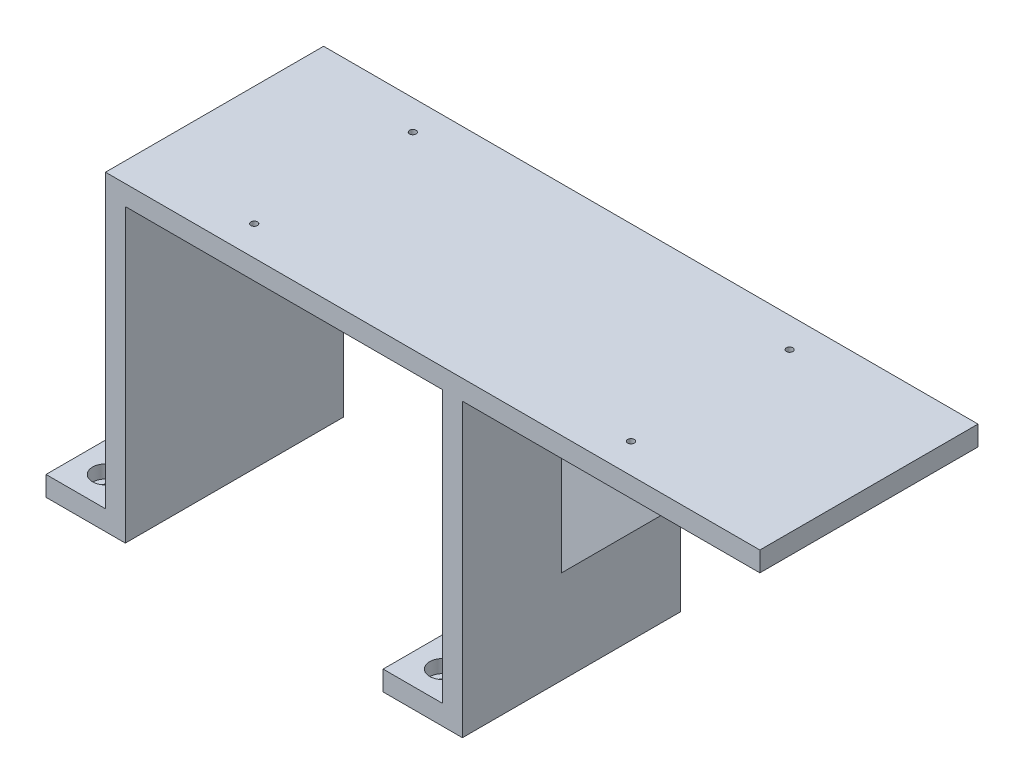
from build123d import *

# Parameters (mm, degrees)
BOSS_EXTRUDE1_DEPTH = 110
SKETCH2_R           = 3.3
CUT_EXTRUDE1_DEPTH  = 11
SKETCH3_R           = 6.5
CUT_EXTRUDE2_DEPTH  = 6.6
SKETCH5_W           = 150
SKETCH5_H           = 10
BOSS_EXTRUDE2_DEPTH = 110
BOSS_EXTRUDE3_DEPTH = 5
M4_TAPPED_HOLE1_D   = 3.3


with BuildPart() as part:
    # Sketch1 → Boss-Extrude1 (new body)
    with BuildSketch(Plane.XY):
        Polygon((0, 0), (30, 0), (30, 147), (210, 147), (210, -10), (170, -10), (170, 0), (200, 0), (200, 137), (40, 137), (40, -10), (0, -10), align=None)
    extrude(amount=BOSS_EXTRUDE1_DEPTH)

    # Sketch2 → Cut-Extrude1 (cut, through all)
    with BuildSketch(Plane(origin=(0, 0, 0), x_dir=(1, 0, 0), z_dir=(0, 1, 0))):
        with Locations((15, -15)):
            Circle(SKETCH2_R)
        with Locations((15, -95)):
            Circle(SKETCH2_R)
        with Locations((185, -95)):
            Circle(SKETCH2_R)
        with Locations((185, -15)):
            Circle(SKETCH2_R)
    extrude(amount=-CUT_EXTRUDE1_DEPTH, mode=Mode.SUBTRACT)

    # Sketch3 → Cut-Extrude2 (cut)
    with BuildSketch(Plane(origin=(0, 0, 0), x_dir=(1, 0, 0), z_dir=(0, 1, 0))):
        with Locations((15, -15)):
            Circle(SKETCH3_R)
        with Locations((15, -95)):
            Circle(SKETCH3_R)
        with Locations((185, -95)):
            Circle(SKETCH3_R)
        with Locations((185, -15)):
            Circle(SKETCH3_R)
    extrude(amount=-CUT_EXTRUDE2_DEPTH, mode=Mode.SUBTRACT)

    # Sketch5 → Boss-Extrude2 (add)
    with BuildSketch(Plane.XY.offset(110)):
        with Locations((285, 142)):
            Rectangle(SKETCH5_W, SKETCH5_H)
    extrude(amount=-BOSS_EXTRUDE2_DEPTH)

    # Sketch6 → Boss-Extrude3 (add, symmetric)
    with BuildSketch(Plane.XY.offset(55)):
        Polygon((210, 37), (310, 137), (210, 137), align=None)
    extrude(amount=BOSS_EXTRUDE3_DEPTH, both=True)

    # M4 Tapped Hole1 (through all)
    with Locations(Plane(origin=(0, 147, 0), x_dir=(1, 0, 0), z_dir=(0, 1, 0))):
        with Locations((90, -15), (280, -15), (280, -95), (90, -95)):
            Hole(M4_TAPPED_HOLE1_D / 2)


solid = part.part
